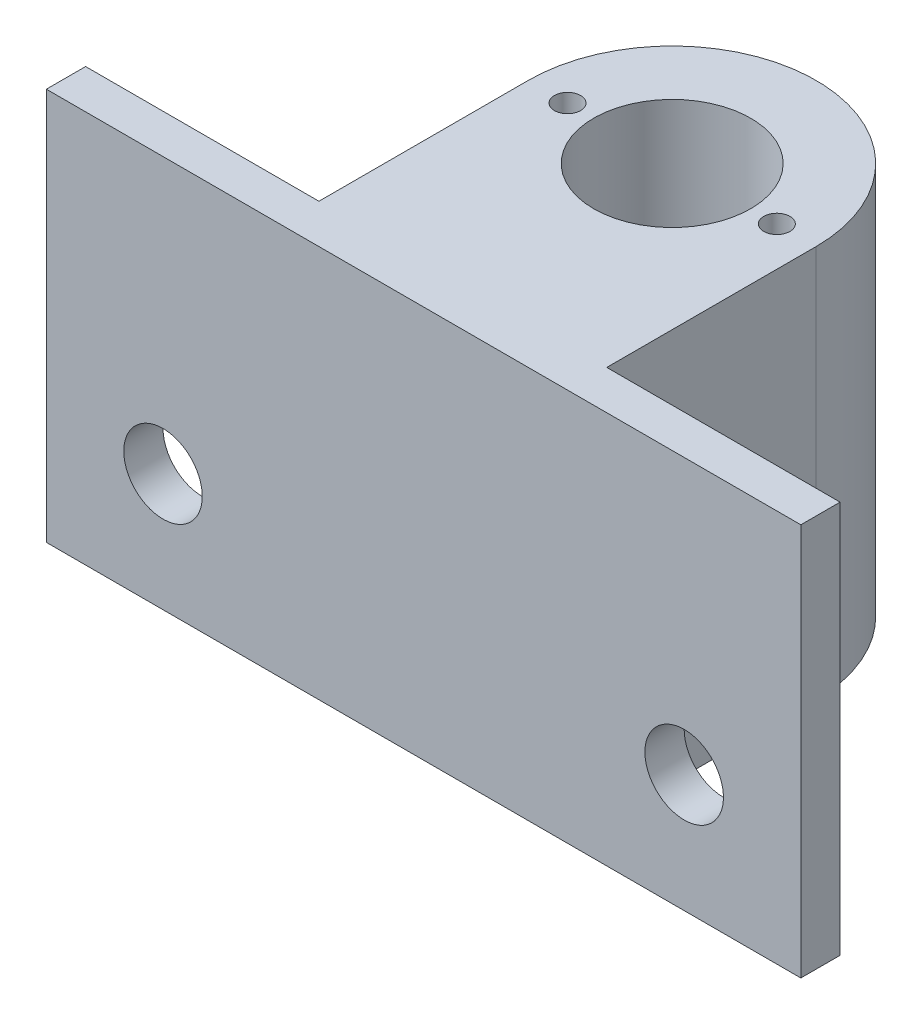
from build123d import *

# Parameters (mm, degrees)
SKETCH1_W           = 57.667844522
SKETCH1_H           = 30
BOSS_EXTRUDE1_DEPTH = 30
SKETCH2_R           = 6
CUT_EXTRUDE2_DEPTH  = 40
CUT_EXTRUDE3_DEPTH  = 31
SKETCH8_R           = 1
CUT_EXTRUDE6_DEPTH  = 10
SKETCH10_R          = 3
CUT_EXTRUDE8_DEPTH  = 10


with BuildPart() as part:
    # Sketch1 → Boss-Extrude1 (new body)
    with BuildSketch(Plane(origin=(0, 0, 0), x_dir=(1, 0, 0), z_dir=(0, 1, 0))):
        Rectangle(SKETCH1_W, SKETCH1_H)
    extrude(amount=BOSS_EXTRUDE1_DEPTH)

    # Sketch2 → Cut-Extrude2 (cut)
    with BuildSketch(Plane(origin=(0, 30, 0), x_dir=(1, 0, 0), z_dir=(0, 1, 0))):
        with Locations((0, 4)):
            Circle(SKETCH2_R)
    extrude(amount=-CUT_EXTRUDE2_DEPTH, mode=Mode.SUBTRACT)

    # Sketch4 → Cut-Extrude3 (cut, through all)
    with BuildSketch(Plane(origin=(0, 30, 0), x_dir=(1, 0, 0), z_dir=(0, 1, 0))):
        with BuildLine():
            ThreePointArc((-4.5e-08, 15), (7.778174577, 11.778174609), (11, 4))
            Line((11, 4), (11, -12))
            Line((11, -12), (28.833922261, -12))
            Line((28.833922261, -12), (28.833922261, 15))
            Line((28.833922261, 15), (-4.5e-08, 15))
        make_face()
        with BuildLine():
            ThreePointArc((-11, 4), (-7.778174609, 11.778174577), (-4.5e-08, 15))
            Line((-4.5e-08, 15), (-28.833922261, 15))
            Line((-28.833922261, 15), (-28.833922261, -12))
            Line((-28.833922261, -12), (-11, -12))
            Line((-11, -12), (-11, 4))
        make_face()
    extrude(amount=-CUT_EXTRUDE3_DEPTH, mode=Mode.SUBTRACT)

    # Sketch8 → Cut-Extrude6 (cut)
    with BuildSketch(Plane(origin=(0, 30, 0), x_dir=(1, 0, 0), z_dir=(0, 1, 0))):
        with Locations((-8, 4)):
            Circle(SKETCH8_R)
        with Locations((8, 4)):
            Circle(SKETCH8_R)
    extrude(amount=-CUT_EXTRUDE6_DEPTH, mode=Mode.SUBTRACT)

    # Sketch10 → Cut-Extrude8 (cut)
    with BuildSketch(Plane(origin=(0, 0, 12), x_dir=(-1, 0, 0), z_dir=(0, 0, -1))):
        with Locations((19.916961131, 9)):
            Circle(SKETCH10_R)
        with Locations((-19.916961131, 9)):
            Circle(SKETCH10_R)
    extrude(amount=-CUT_EXTRUDE8_DEPTH, mode=Mode.SUBTRACT)


solid = part.part
